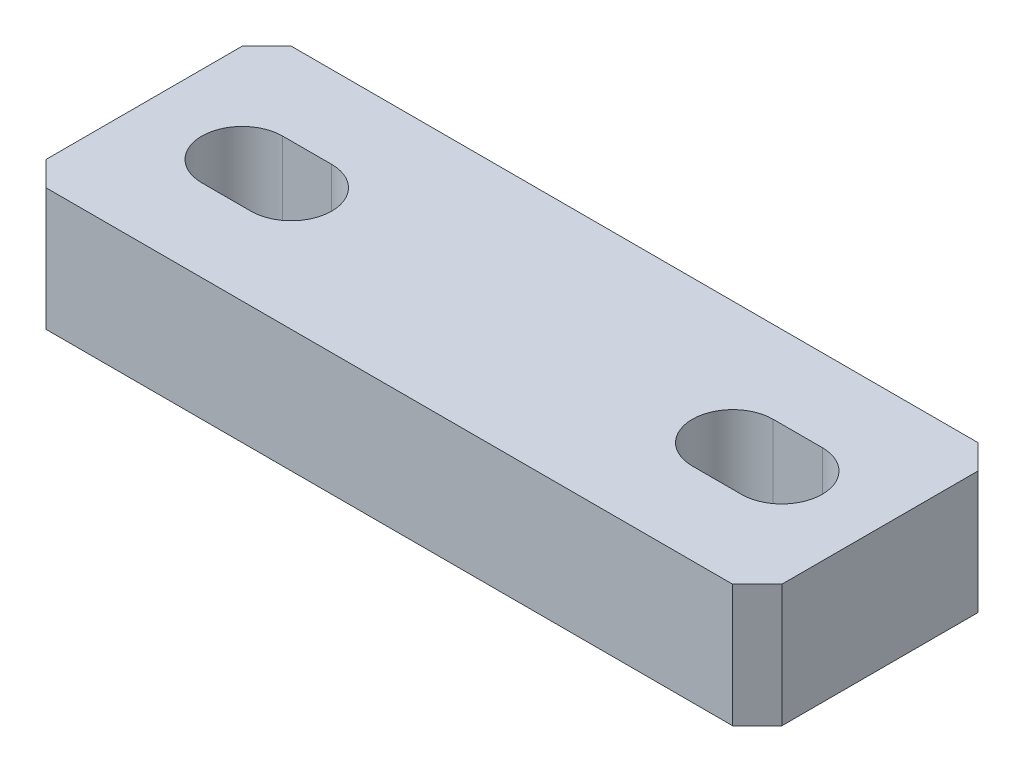
from build123d import *

# Parameters (mm, degrees)
SCHIZZO1_W                   = 30
SCHIZZO1_H                   = 5
ESTRUSIONE_ESTRUSIONE1_DEPTH = 10
TAGLIO_ESTRUSIONE1_DEPTH     = 10
SMUSSO1_SIZE                 = 1
SMUSSO2_SIZE                 = 1


with BuildPart() as part:
    # Schizzo1 → Estrusione-Estrusione1 (new body)
    with BuildSketch(Plane.XY):
        with Locations((0, 2.5)):
            Rectangle(SCHIZZO1_W, SCHIZZO1_H)
    extrude(amount=ESTRUSIONE_ESTRUSIONE1_DEPTH)

    # Schizzo2 → Taglio-Estrusione1 (cut)
    with BuildSketch(Plane(origin=(0, 5, 0), x_dir=(1, 0, 0), z_dir=(0, 1, 0))):
        with BuildLine():
            Line((-11, -3.35), (-9, -3.35))
            ThreePointArc((-9, -3.35), (-7.35, -5), (-9, -6.65))
            Line((-9, -6.65), (-11, -6.65))
            ThreePointArc((-11, -6.65), (-12.65, -5), (-11, -3.35))
        make_face()
        with BuildLine():
            Line((11, -3.35), (9, -3.35))
            ThreePointArc((9, -3.35), (7.35, -5), (9, -6.65))
            Line((9, -6.65), (11, -6.65))
            ThreePointArc((11, -6.65), (12.65, -5), (11, -3.35))
        make_face()
    extrude(amount=-TAGLIO_ESTRUSIONE1_DEPTH, mode=Mode.SUBTRACT)

    # Smusso1
    smusso1_edges = [part.edges().sort_by_distance(p)[0] for p in [
        (-15, 2.5, 10),
    ]]
    chamfer(smusso1_edges, length=SMUSSO1_SIZE)

    # Smusso2
    smusso2_edges = [part.edges().sort_by_distance(p)[0] for p in [
        (15, 2.5, 10),
        (15, 2.5, 0),
        (-15, 2.5, 0),
    ]]
    chamfer(smusso2_edges, length=SMUSSO2_SIZE)


solid = part.part
